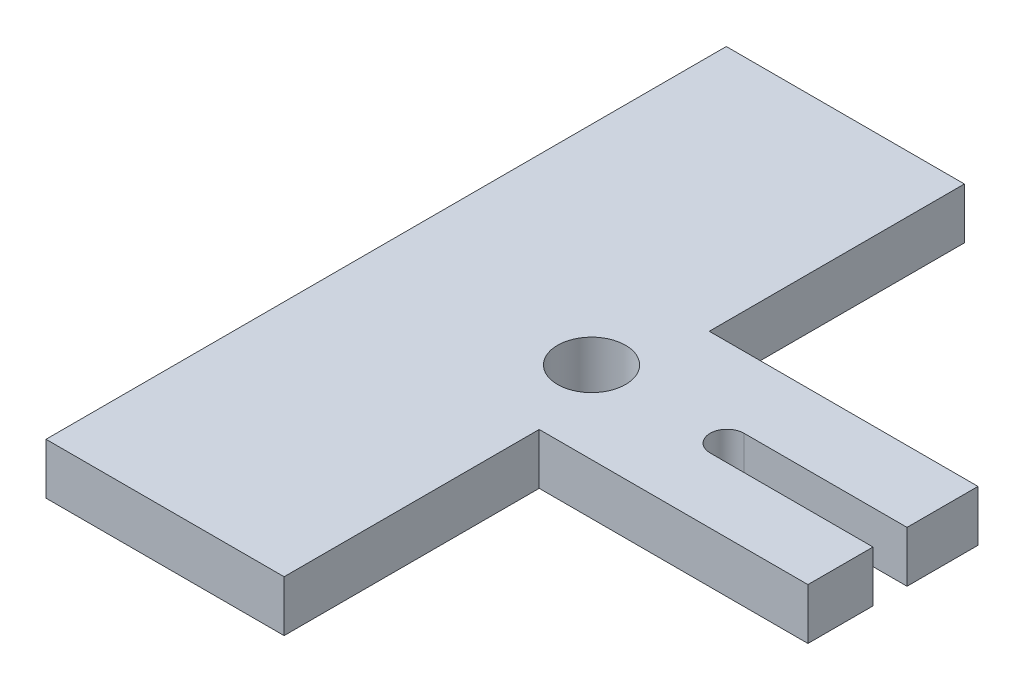
from build123d import *

# Parameters (mm, degrees)
SKETCH1_W           = 15
SKETCH1_H           = 20
BOSS_EXTRUDE1_DEPTH = 1.5
SKETCH2_R           = 1
CUT_EXTRUDE1_DEPTH  = 1.5
CUT_EXTRUDE2_DEPTH  = 1.5
CUT_EXTRUDE3_DEPTH  = 1.5


with BuildPart() as part:
    # Sketch1 → Boss-Extrude1 (new body)
    with BuildSketch(Plane(origin=(0, 0, 0), x_dir=(1, 0, 0), z_dir=(0, 1, 0))):
        with Locations((-8.746418338, 3.724928367)):
            Rectangle(SKETCH1_W, SKETCH1_H)
    extrude(amount=BOSS_EXTRUDE1_DEPTH)

    # Sketch2 → Cut-Extrude1 (cut)
    with BuildSketch(Plane(origin=(0, 1.5, 0), x_dir=(1, 0, 0), z_dir=(0, 1, 0))):
        with Locations((-10.120989787, 3.638381578)):
            Circle(SKETCH2_R)
    extrude(amount=-CUT_EXTRUDE1_DEPTH, mode=Mode.SUBTRACT)

    # Sketch3 → Cut-Extrude2 (cut)
    with BuildSketch(Plane(origin=(0, 1.5, 0), x_dir=(1, 0, 0), z_dir=(0, 1, 0))):
        Polygon((-9.246418338, -6.275071633), (-9.246418338, -7.482454252), (1.99298081, -6.056034197), (1.99298081, 15.151348422), (-9.246418338, 13.724928367), (-9.246418338, 6.224928381), (-1.346418338, 6.224928381), (-1.346418338, 1.224928353), (-9.246418338, 1.224928353), align=None)
    extrude(amount=-CUT_EXTRUDE2_DEPTH, mode=Mode.SUBTRACT)

    # Sketch4 → Cut-Extrude3 (cut)
    with BuildSketch(Plane(origin=(0, 1.5, 0), x_dir=(1, 0, 0), z_dir=(0, 1, 0))):
        with BuildLine():
            Line((-6.136798849, 4.138381578), (-0.966349773, 4.138381578))
            Line((-0.966349773, 4.138381578), (-0.966349773, 3.138381578))
            Line((-0.966349773, 3.138381578), (-6.136798849, 3.138381578))
            ThreePointArc((-6.136798849, 3.138381578), (-6.636798849, 3.638381578), (-6.136798849, 4.138381578))
        make_face()
    extrude(amount=-CUT_EXTRUDE3_DEPTH, mode=Mode.SUBTRACT)


solid = part.part
